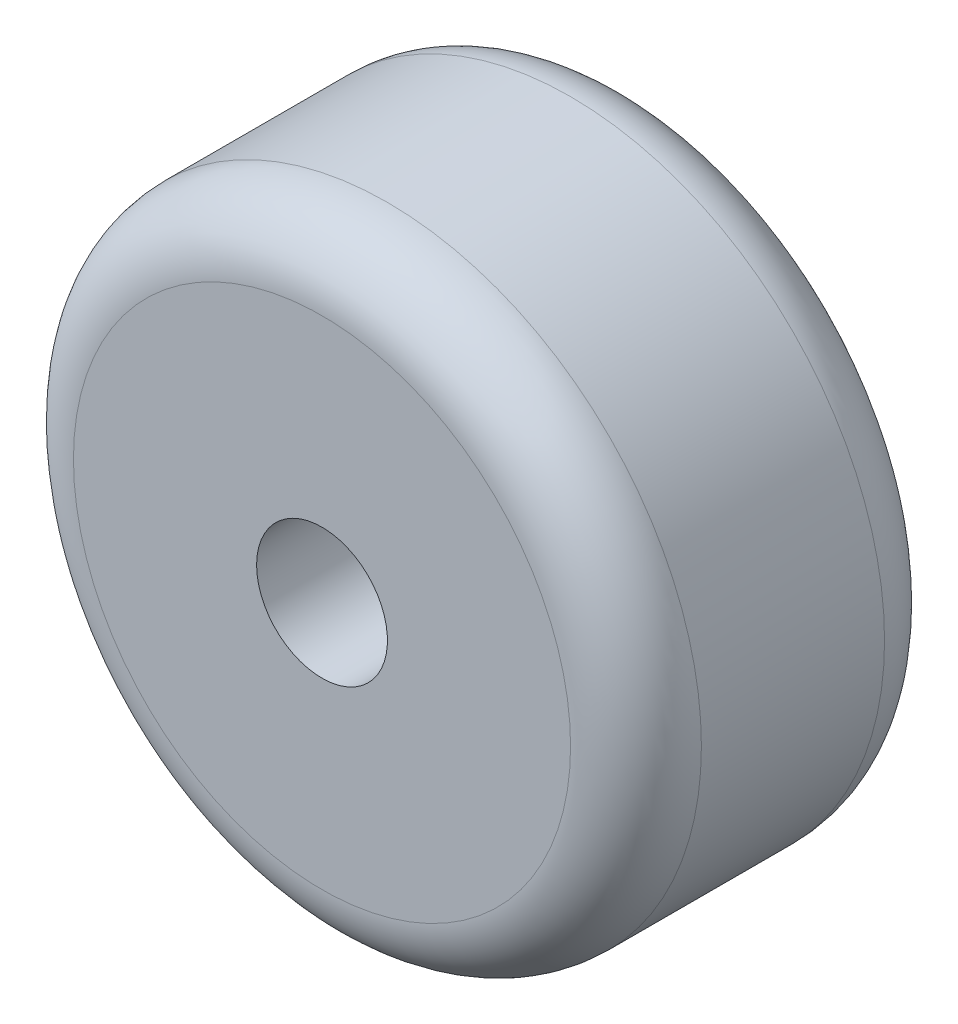
from build123d import *

# Parameters (mm, degrees)
SKIZZE1_R                       = 24
AUFSATZ_LINEAR_AUSTRAGEN1_DEPTH = 24
VERRUNDUNG1_R                   = 5
SKIZZE2_R                       = 5
SCHNITT_LINEAR_AUSTRAGEN1_DEPTH = 25


with BuildPart() as part:
    # Skizze1 → Aufsatz-Linear austragen1 (new body)
    with BuildSketch(Plane.XY):
        Circle(SKIZZE1_R)
    extrude(amount=AUFSATZ_LINEAR_AUSTRAGEN1_DEPTH)

    # Verrundung1
    verrundung1_edges = [part.edges().sort_by_distance(p)[0] for p in [
        (-24, 0, 0),
        (-24, 0, 24),
    ]]
    fillet(verrundung1_edges, radius=VERRUNDUNG1_R)

    # Skizze2 → Schnitt-Linear austragen1 (cut, through all)
    with BuildSketch(Plane(origin=(0, 0, 0), x_dir=(-1, 0, 0), z_dir=(0, 0, -1))):
        Circle(SKIZZE2_R)
    extrude(amount=-SCHNITT_LINEAR_AUSTRAGEN1_DEPTH, mode=Mode.SUBTRACT)


solid = part.part
